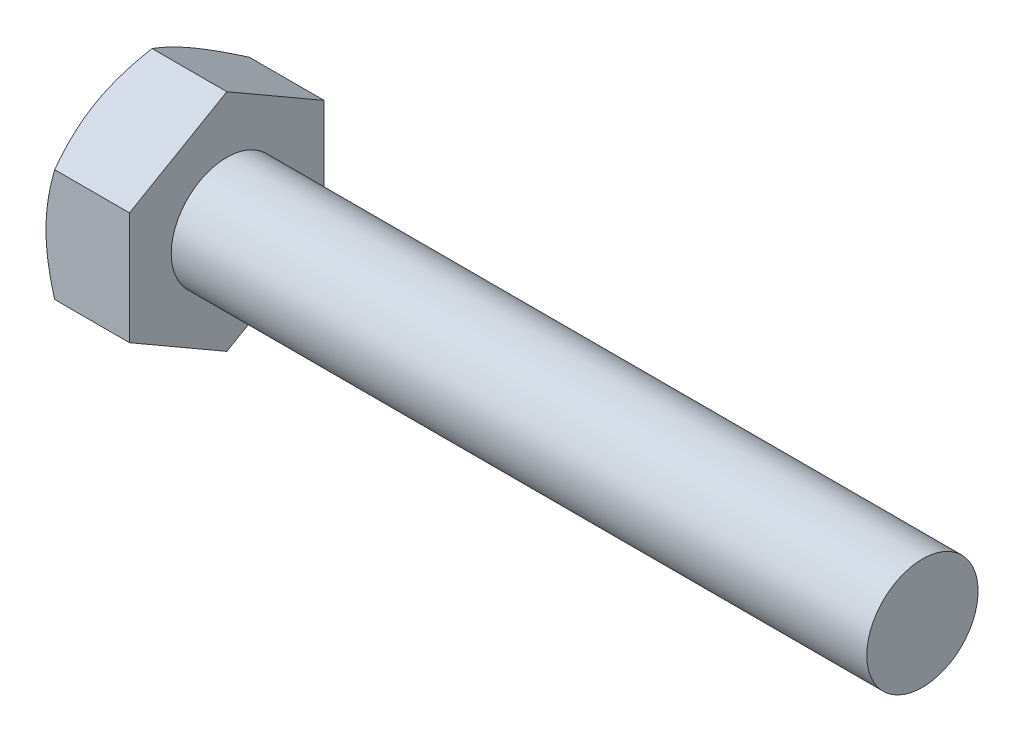
from build123d import *

# Parameters (mm, degrees)
SKETCH2_R     = 4.081986143
HEX_DIE_DEPTH = 3
SKETCH4_R     = 3.0625
INDENT_DEPTH  = 0.375


with BuildPart() as part:
    # BodySke → Base-Revolve (revolve)
    with BuildSketch(Plane.XY):
        Polygon((3, 2), (3, 4.041570439), (0.312675839, 4.041570439), (0, 3.5), (0, 0), (28, 0), (28, 2), align=None)
    revolve(axis=Axis((-25.4, 0, 0), (1, 0, 0)))

    # Sketch2 → Hex-Die (cut)
    with BuildSketch(Plane(origin=(0, 0, 0), x_dir=(0, 0, -1), z_dir=(1, 0, 0))):
        Circle(SKETCH2_R)
        Polygon((-3.5, 2.020725951), (0, 4.041451902), (3.5, 2.020725951), (3.5, -2.020725951), (0, -4.041451902), (-3.5, -2.020725951), align=None, mode=Mode.SUBTRACT)
    extrude(amount=HEX_DIE_DEPTH, mode=Mode.SUBTRACT)

    # Sketch4 → Indent (cut)
    with BuildSketch(Plane(origin=(0, 0, 0), x_dir=(0, 0, -1), z_dir=(1, 0, 0))):
        Circle(SKETCH4_R)
    extrude(amount=INDENT_DEPTH, mode=Mode.SUBTRACT)


solid = part.part
